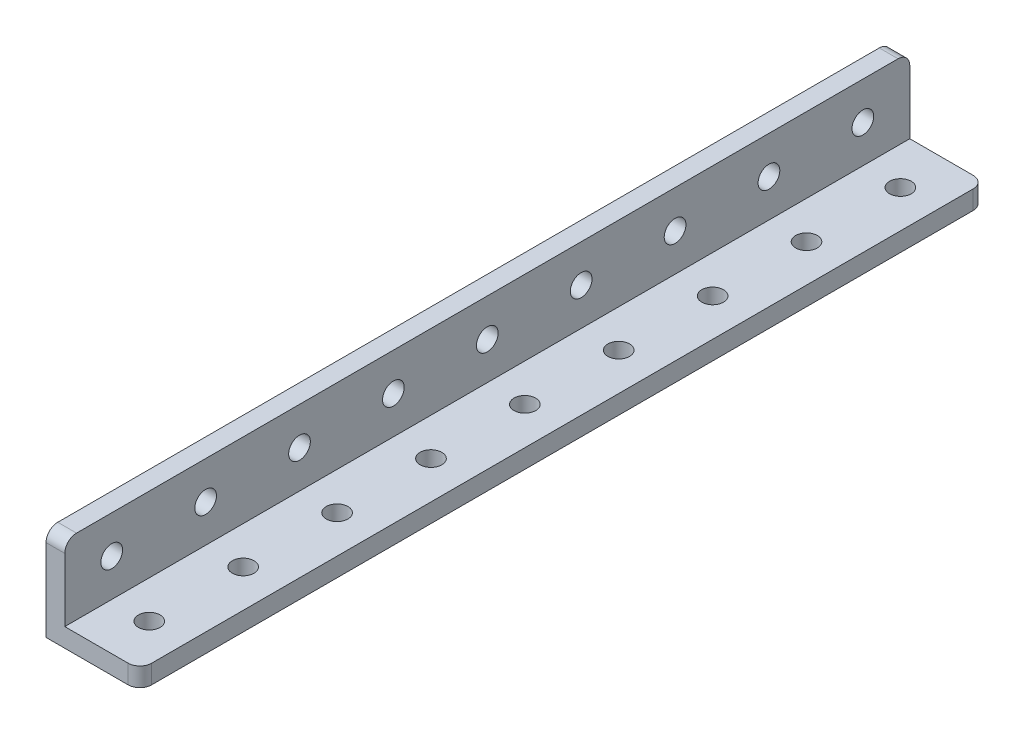
from build123d import *

# Parameters (mm, degrees)
SKETCH1_W                      = 144
SKETCH1_H                      = 16
BOSS_EXTRUDE1_DEPTH            = 16
SKETCH2_W                      = 12.8
SKETCH2_H                      = 12.8
CUT_EXTRUDE1_DEPTH             = 145
F_3_7_3_7_DIAMETER_HOLE1_D     = 3.7
F_3_7_3_7_DIAMETER_HOLE1_DEPTH = 16
F_3_7_3_7_DIAMETER_HOLE2_D     = 3.7
F_3_7_3_7_DIAMETER_HOLE2_DEPTH = 16
FILLET1_R                      = 2


with BuildPart() as part:
    # Sketch1 → Boss-Extrude1 (new body)
    with BuildSketch(Plane(origin=(16, 0, 0), x_dir=(0, 0, -1), z_dir=(1, 0, 0))):
        with Locations((72, 8)):
            Rectangle(SKETCH1_W, SKETCH1_H)
    extrude(amount=-BOSS_EXTRUDE1_DEPTH)

    # Sketch2 → Cut-Extrude1 (cut, through all)
    with BuildSketch(Plane.XY):
        with Locations((9.6, 9.6)):
            Rectangle(SKETCH2_W, SKETCH2_H)
    extrude(amount=-CUT_EXTRUDE1_DEPTH, mode=Mode.SUBTRACT)

    # Ø3.7 (3.7) Diameter Hole1
    with Locations(Plane.ZY):
        with Locations((-24, 9.6), (-40, 9.6), (-56, 9.6), (-72, 9.6), (-88, 9.6), (-104, 9.6), (-120, 9.6), (-136, 9.6), (-8, 9.6)):
            Hole(F_3_7_3_7_DIAMETER_HOLE1_D / 2, depth=F_3_7_3_7_DIAMETER_HOLE1_DEPTH)

    # Ø3.7 (3.7) Diameter Hole2
    with Locations(Plane(origin=(0, 0, 0), x_dir=(-1, 0, 0), z_dir=(0, -1, 0))):
        with Locations((-9.6, 24), (-9.6, 40), (-9.6, 56), (-9.6, 72), (-9.6, 88), (-9.6, 104), (-9.6, 120), (-9.6, 136), (-9.6, 8)):
            Hole(F_3_7_3_7_DIAMETER_HOLE2_D / 2, depth=F_3_7_3_7_DIAMETER_HOLE2_DEPTH)

    # Fillet1
    fillet1_edges = [part.edges().sort_by_distance(p)[0] for p in [
        (16, 1.6, 0),
        (16, 1.6, -144),
        (1.6, 16, 0),
        (1.6, 16, -144),
    ]]
    fillet(fillet1_edges, radius=FILLET1_R)


solid = part.part
